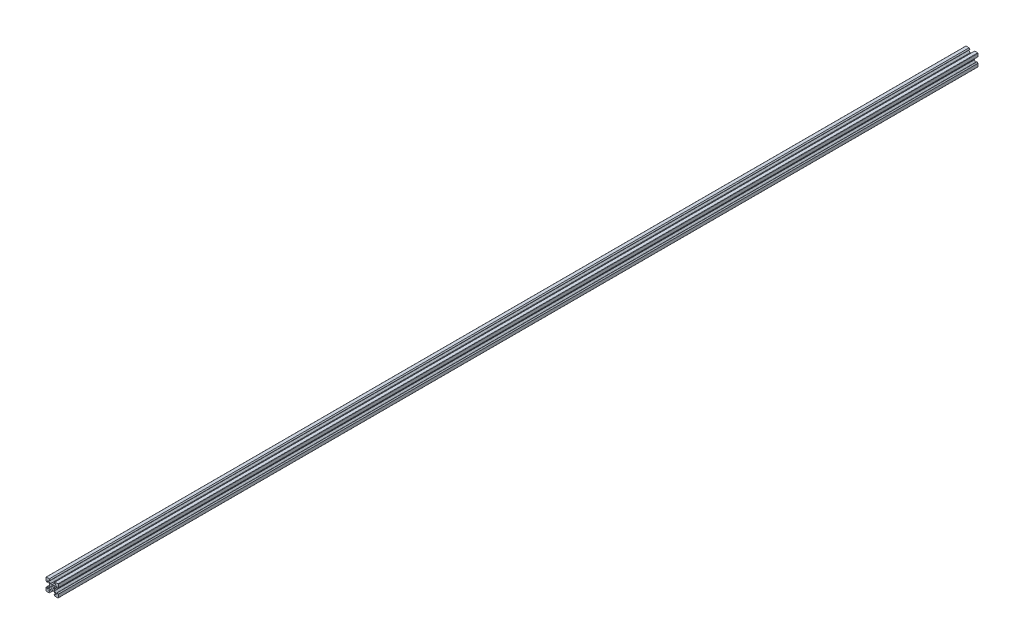
from build123d import *

# Parameters (mm, degrees)
SKETCH1_R           = 2.1
BOSS_EXTRUDE1_DEPTH = 1500


with BuildPart() as part:
    # Sketch1 → Boss-Extrude1 (new body)
    with BuildSketch(Plane.XY):
        with BuildLine():
            Line((4.58, -10), (9.5, -10))
            ThreePointArc((9.5, -10), (9.853553391, -9.853553391), (10, -9.5))
            Line((10, -9.5), (10, -4.58))
            Line((10, -4.58), (8.545, -3.125))
            Line((8.545, -3.125), (8.2, -3.125))
            Line((8.2, -3.125), (8.2, -5.5))
            Line((8.2, -5.5), (6.560660172, -5.5))
            Line((6.560660172, -5.5), (3.9, -2.839339828))
            Line((3.9, -2.839339828), (3.9, -0.21))
            Line((3.9, -0.21), (3.69, 0))
            Line((3.69, 0), (3.9, 0.21))
            Line((3.9, 0.21), (3.9, 2.839339828))
            Line((3.9, 2.839339828), (6.560660172, 5.5))
            Line((6.560660172, 5.5), (8.2, 5.5))
            Line((8.2, 5.5), (8.2, 3.125))
            Line((8.2, 3.125), (8.545, 3.125))
            Line((8.545, 3.125), (10, 4.58))
            Line((10, 4.58), (10, 9.5))
            ThreePointArc((10, 9.5), (9.853553391, 9.853553391), (9.5, 10))
            Line((9.5, 10), (4.58, 10))
            Line((4.58, 10), (3.125, 8.545))
            Line((3.125, 8.545), (3.125, 8.2))
            Line((3.125, 8.2), (5.5, 8.2))
            Line((5.5, 8.2), (5.5, 6.560660172))
            Line((5.5, 6.560660172), (2.839339828, 3.9))
            Line((2.839339828, 3.9), (0.21, 3.9))
            Line((0.21, 3.9), (0, 3.69))
            Line((0, 3.69), (-0.21, 3.9))
            Line((-0.21, 3.9), (-2.839339828, 3.9))
            Line((-2.839339828, 3.9), (-5.5, 6.560660172))
            Line((-5.5, 6.560660172), (-5.5, 8.2))
            Line((-5.5, 8.2), (-3.125, 8.2))
            Line((-3.125, 8.2), (-3.125, 8.545))
            Line((-3.125, 8.545), (-4.58, 10))
            Line((-4.58, 10), (-9.5, 10))
            ThreePointArc((-9.5, 10), (-9.853553391, 9.853553391), (-10, 9.5))
            Line((-10, 9.5), (-10, 4.58))
            Line((-10, 4.58), (-8.545, 3.125))
            Line((-8.545, 3.125), (-8.2, 3.125))
            Line((-8.2, 3.125), (-8.2, 5.5))
            Line((-8.2, 5.5), (-6.560660172, 5.5))
            Line((-6.560660172, 5.5), (-3.9, 2.839339828))
            Line((-3.9, 2.839339828), (-3.9, 0.21))
            Line((-3.9, 0.21), (-3.69, 0))
            Line((-3.69, 0), (-3.9, -0.21))
            Line((-3.9, -0.21), (-3.9, -2.839339828))
            Line((-3.9, -2.839339828), (-6.560660172, -5.5))
            Line((-6.560660172, -5.5), (-8.2, -5.5))
            Line((-8.2, -5.5), (-8.2, -3.125))
            Line((-8.2, -3.125), (-8.545, -3.125))
            Line((-8.545, -3.125), (-10, -4.58))
            Line((-10, -4.58), (-10, -9.5))
            ThreePointArc((-10, -9.5), (-9.853553391, -9.853553391), (-9.5, -10))
            Line((-9.5, -10), (-4.58, -10))
            Line((-4.58, -10), (-3.125, -8.545))
            Line((-3.125, -8.545), (-3.125, -8.2))
            Line((-3.125, -8.2), (-5.5, -8.2))
            Line((-5.5, -8.2), (-5.5, -6.560660172))
            Line((-5.5, -6.560660172), (-2.839339828, -3.9))
            Line((-2.839339828, -3.9), (-0.21, -3.9))
            Line((-0.21, -3.9), (0, -3.69))
            Line((0, -3.69), (0.21, -3.9))
            Line((0.21, -3.9), (2.839339828, -3.9))
            Line((2.839339828, -3.9), (5.5, -6.560660172))
            Line((5.5, -6.560660172), (5.5, -8.2))
            Line((5.5, -8.2), (3.125, -8.2))
            Line((3.125, -8.2), (3.125, -8.545))
            Line((3.125, -8.545), (4.58, -10))
        make_face()
        Circle(SKETCH1_R, mode=Mode.SUBTRACT)
    extrude(amount=BOSS_EXTRUDE1_DEPTH)


solid = part.part
